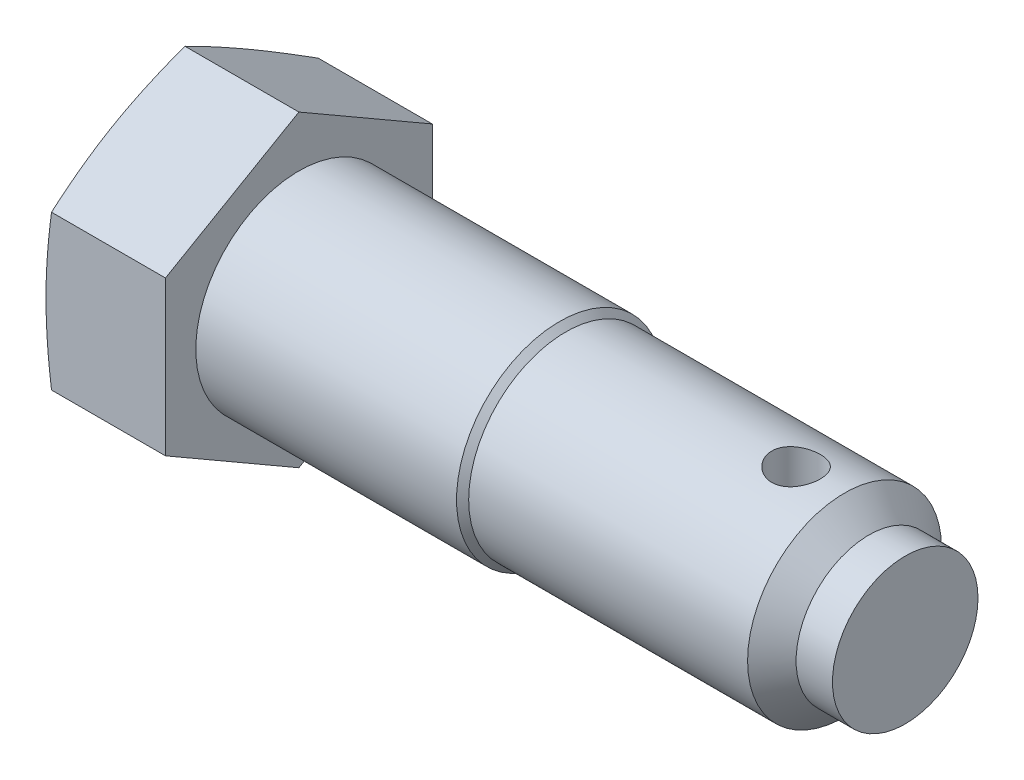
from build123d import *

# Parameters (mm, degrees)
BASEHEAD_DEPTH  = 10
SKE2_R          = 2
HOLE_DEPTH      = 13.701705922
HOLE_DEPTH_BACK = 13.701705922


with BuildPart() as part:
    # BodySke → BaseBody (revolve)
    with BuildSketch(Plane.XY):
        Polygon((0, 0), (0, 8.5), (21.5, 8.5), (22, 8), (45, 8), (47, 6), (50, 6), (50, 0), align=None)
    revolve(axis=Axis((0, 0, 0), (-1, 0, 0)))

    # Ske → BaseHead (add)
    with BuildSketch(Plane.ZY):
        Polygon((0, 12.701705922), (-11, 6.350852961), (-11, -6.350852961), (0, -12.701705922), (11, -6.350852961), (11, 6.350852961), align=None)
    extrude(amount=BASEHEAD_DEPTH)

    # Ske1 → HeadFillet (revolve, cut)
    with BuildSketch(Plane.XY):
        Polygon((-10, 12.701705922), (-9.396657217, 12.701705922), (-10, 10.45), align=None)
    revolve(axis=Axis((0, 0, 0), (-1, 0, 0)), mode=Mode.SUBTRACT)

    # Ske2 → Hole (cut, two sides)
    with BuildSketch(Plane(origin=(0, 0, 0), x_dir=(1, 0, 0), z_dir=(0, 1, 0))) as hole_sk:
        with Locations((41, 0)):
            Circle(SKE2_R)
    extrude(amount=HOLE_DEPTH, mode=Mode.SUBTRACT)
    extrude(hole_sk.sketch, amount=-HOLE_DEPTH_BACK, mode=Mode.SUBTRACT)


solid = part.part
